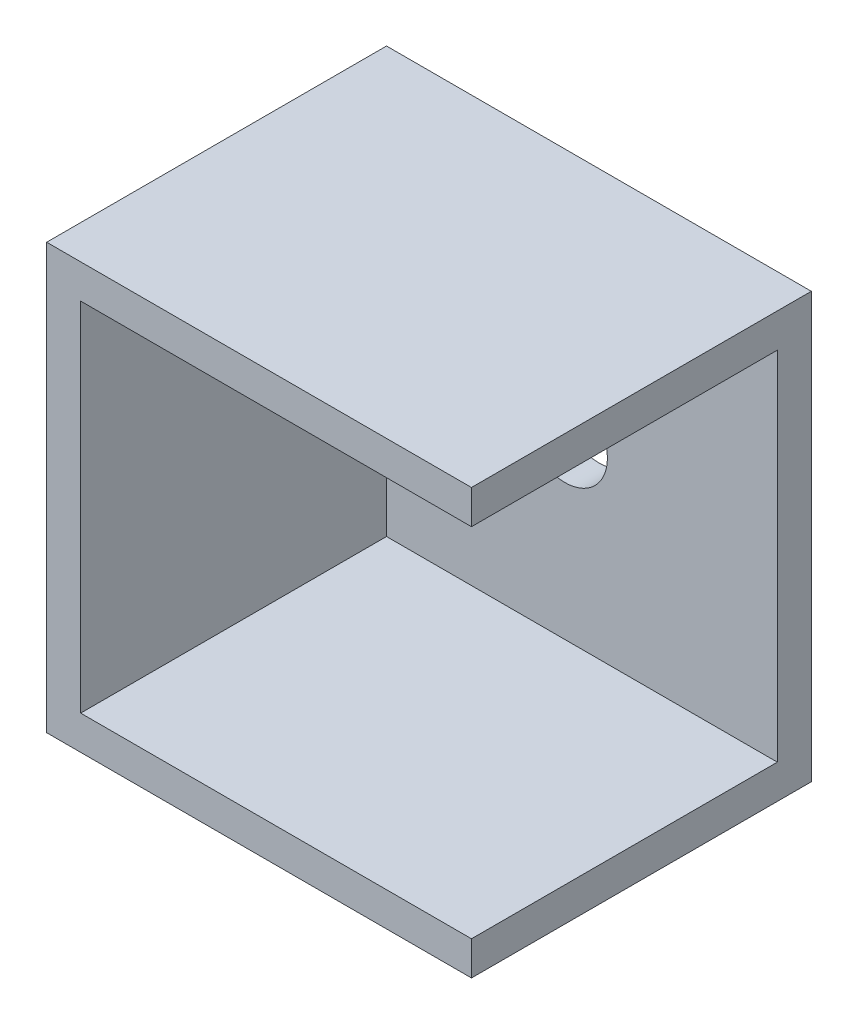
from build123d import *

# Parameters (mm, degrees)
IZIM1_W                     = 25
IZIM1_H                     = 25
Y_KSEKLIK_EKSTR_ZYON1_DEPTH = 20
BO_ALTMA1_T                 = -2
IZIM2_R                     = 2.5
KES_EKSTR_ZYON1_DEPTH       = 5


with BuildPart() as part:
    # Çizim1 → Yükseklik-Ekstrüzyon1 (new body)
    with BuildSketch(Plane.XY):
        Rectangle(IZIM1_W, IZIM1_H)
    extrude(amount=Y_KSEKLIK_EKSTR_ZYON1_DEPTH)

    # İç Boşaltma1
    bo_altma1_openings = [part.faces().sort_by_distance(p)[0] for p in [
        (0, 0, 20),
        (12.5, 0, 10),
    ]]
    offset(amount=BO_ALTMA1_T, openings=bo_altma1_openings, kind=Kind.INTERSECTION)

    # Çizim2 → Kes-Ekstrüzyon1 (cut)
    with BuildSketch(Plane.XY.offset(2)):
        Circle(IZIM2_R)
    extrude(amount=-KES_EKSTR_ZYON1_DEPTH, mode=Mode.SUBTRACT)


solid = part.part
